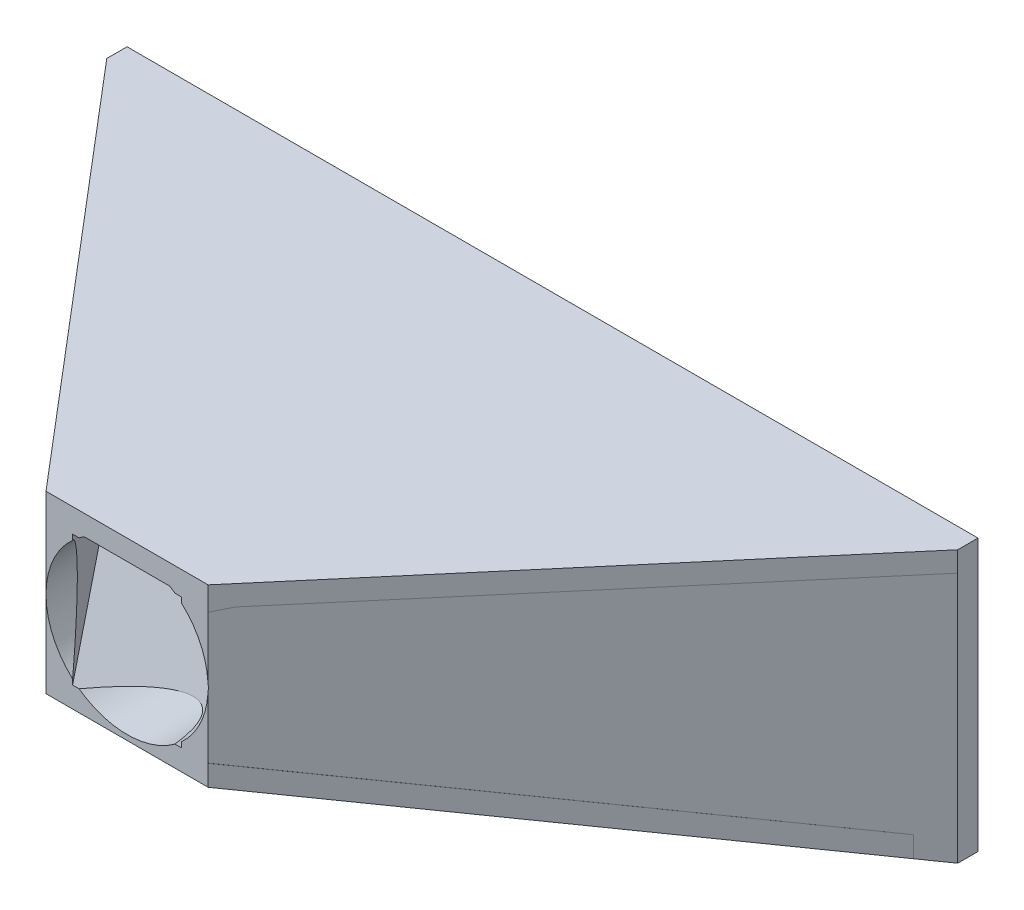
from build123d import *

# Parameters (mm, degrees)
ESQUISSE1_W                  = 210
ESQUISSE1_H                  = 90
ESQUISSE1_W_2                = 200
ESQUISSE1_H_2                = 80
BOSS_EXTRU_1_DEPTH           = 5
ESQUISSE2_R                  = 20
ESQUISSE2_R_2                = 15
BOSS_EXTRU_2_DEPTH           = 5
BOSS_EXTRU_3_DEPTH           = 90
BOSS_EXTRU_4_DEPTH           = 200
ESQUISSE6_W                  = 26.875595252
ESQUISSE6_H                  = 32.252188949
ENL_V_MAT_EXTRU_1_DEPTH      = 200
ENL_V_MAT_EXTRU_2_DEPTH      = 200
ENL_V_MAT_EXTRU_3_DEPTH      = 237
ESQUISSE10_R                 = 20
ENL_V_MAT_EXTRU_4_DEPTH      = 6
ENL_V_MAT_EXTRU_4_DEPTH_BACK = 106
ESQUISSE11_W                 = 294.385058415
ESQUISSE11_H                 = 160.265549893
ENL_V_MAT_EXTRU_5_DEPTH      = 23
ENL_V_MAT_EXTRU_5_DEPTH_BACK = 16
BOSS_EXTRU_5_DEPTH           = 5


with BuildPart() as part:
    # Esquisse1 → Boss.-Extru.1 (new body)
    with BuildSketch(Plane.XY):
        with Locations((100, -26.819835627)):
            Rectangle(ESQUISSE1_W, ESQUISSE1_H)
        with Locations((100, -26.819835627)):
            Rectangle(ESQUISSE1_W_2, ESQUISSE1_H_2, mode=Mode.SUBTRACT)
    extrude(amount=BOSS_EXTRU_1_DEPTH)



with BuildPart() as body_2:
    # Esquisse2 → Boss.-Extru.2 (new body)
    with BuildSketch(Plane.XY.offset(105)):
        with Locations((100, -26.819835627)):
            Circle(ESQUISSE2_R)
        with Locations((100, -26.819835627)):
            Circle(ESQUISSE2_R_2, mode=Mode.SUBTRACT)
    extrude(amount=BOSS_EXTRU_2_DEPTH)


with BuildPart() as part_1:
    add(part.part)

    add(body_2.part)  # Boss.-Extru.3 merges body 2
    # Esquisse3 → Boss.-Extru.3 (add)
    with BuildSketch(Plane.XZ.offset(71.819835627)):
        Polygon((113.437797626, 105), (198.437797626, 5), (205, 5), (119.954563332, 105), align=None)
        Polygon((80, 105), (-5, 5), (1.562202374, 5), (86.562202374, 105), align=None)
    extrude(amount=-BOSS_EXTRU_3_DEPTH)

    # Esquisse5 → Boss.-Extru.4 (add)
    with BuildSketch(Plane.ZY.offset(-200)):
        Polygon((5, 18.180164373), (105, -5.554833167), (105, -10.693741152), (5, 13.041256389), align=None)
        Polygon((5, -71.819835627), (105, -48.084838086), (105, -42.945930101), (5, -66.680927642), align=None)
    extrude(amount=BOSS_EXTRU_4_DEPTH)

    # Esquisse6 → Enlèv. mat.-Extru.1 (cut)
    with BuildSketch(Plane(origin=(0, 0, 105), x_dir=(-1, 0, 0), z_dir=(0, 0, -1))):
        with Locations((-100, -26.819835627)):
            Rectangle(ESQUISSE6_W, ESQUISSE6_H)
    extrude(amount=-ENL_V_MAT_EXTRU_1_DEPTH, mode=Mode.SUBTRACT)

    # Esquisse8 → Enlèv. mat.-Extru.2 (cut)
    with BuildSketch(Plane.XZ.offset(71.819835627)):
        Polygon((0, 105), (80, 105), (0, 10.882352941), align=None)
        Polygon((120, 105), (200, 10.882352941), (200, 105), align=None)
    extrude(amount=-ENL_V_MAT_EXTRU_2_DEPTH, mode=Mode.SUBTRACT)

    # Esquisse9 → Enlèv. mat.-Extru.3 (cut)
    with BuildSketch(Plane.ZY.offset(5)):
        Polygon((105, 18.180164373), (105, -5.554833167), (5, 18.180164373), align=None)
        Polygon((5, -71.819835627), (105, -71.819835627), (105, -48.084838086), align=None)
    extrude(amount=-ENL_V_MAT_EXTRU_3_DEPTH, mode=Mode.SUBTRACT)

    # Esquisse10 → Enlèv. mat.-Extru.4 (cut, two sides)
    with BuildSketch(Plane.XY.offset(105)) as enl_v_mat_extru_4_sk:
        with Locations((100, -26.819835627)):
            Circle(ESQUISSE10_R)
    extrude(amount=ENL_V_MAT_EXTRU_4_DEPTH, mode=Mode.SUBTRACT)
    extrude(enl_v_mat_extru_4_sk.sketch, amount=-ENL_V_MAT_EXTRU_4_DEPTH_BACK, mode=Mode.SUBTRACT)

    # Esquisse11 → Enlèv. mat.-Extru.5 (cut, two sides)
    with BuildSketch(Plane(origin=(0, 13.180164373, 0), x_dir=(-1, 0, 0), z_dir=(0, -1, 0))) as enl_v_mat_extru_5_sk:
        with Locations((-99.239876108, -40.996630143)):
            Rectangle(ESQUISSE11_W, ESQUISSE11_H)
    extrude(amount=ENL_V_MAT_EXTRU_5_DEPTH, mode=Mode.SUBTRACT)
    extrude(enl_v_mat_extru_5_sk.sketch, amount=-ENL_V_MAT_EXTRU_5_DEPTH_BACK, mode=Mode.SUBTRACT)

    # Esquisse12 → Boss.-Extru.5 (add)
    with BuildSketch(Plane(origin=(0, -9.819835627, 0), x_dir=(1, 0, 0), z_dir=(0, 1, 0))):
        Polygon((-5, -5), (-5, 0), (205, 0), (205, -5), (120, -105), (80, -105), align=None)
    extrude(amount=BOSS_EXTRU_5_DEPTH)


solid = part_1.part
